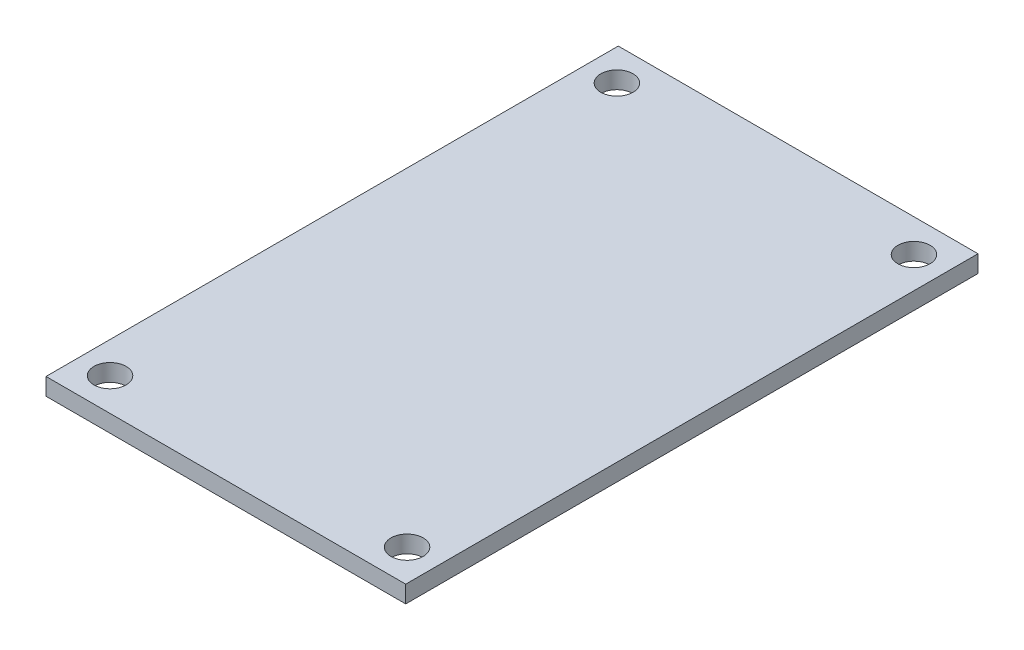
from build123d import *

# Parameters (mm, degrees)
SKETCH1_W           = 33.528
SKETCH1_H           = 53.34
SKETCH1_R           = 1.5
BOSS_EXTRUDE1_DEPTH = 1.6


with BuildPart() as part:
    # Sketch1 → Boss-Extrude1 (new body)
    with BuildSketch(Plane(origin=(0, 0, 0), x_dir=(1, 0, 0), z_dir=(0, 1, 0))):
        Rectangle(SKETCH1_W, SKETCH1_H)
        with Locations((-13.843, 23.622)):
            Circle(SKETCH1_R, mode=Mode.SUBTRACT)
        with Locations((13.843, 23.622)):
            Circle(SKETCH1_R, mode=Mode.SUBTRACT)
        with Locations((13.843, -23.622)):
            Circle(SKETCH1_R, mode=Mode.SUBTRACT)
        with Locations((-13.843, -23.622)):
            Circle(SKETCH1_R, mode=Mode.SUBTRACT)
    extrude(amount=BOSS_EXTRUDE1_DEPTH)


solid = part.part
